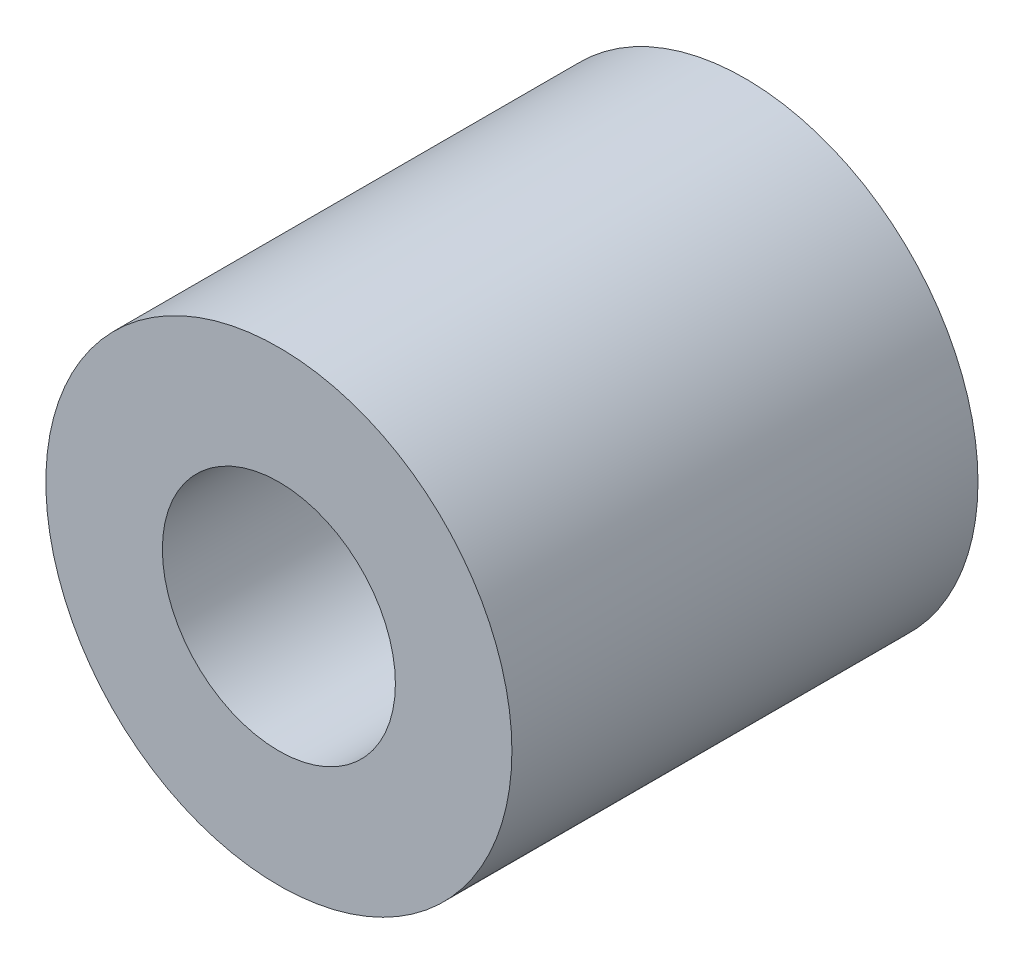
from build123d import *

# Parameters (mm, degrees)
SKETCH_1_R          = 4
EXTRUDE_1_DEPTH     = 8
SKETCH_2_R          = 2
CUT_EXTRUDE_1_DEPTH = 15


with BuildPart() as part:
    # 草图1 → 凸台-拉伸1 (new body)
    with BuildSketch(Plane.XY):
        Circle(SKETCH_1_R)
    extrude(amount=EXTRUDE_1_DEPTH)

    # 草图2 → 切除-拉伸1 (cut)
    with BuildSketch(Plane.XY.offset(8)):
        Circle(SKETCH_2_R)
    extrude(amount=-CUT_EXTRUDE_1_DEPTH, mode=Mode.SUBTRACT)


solid = part.part
